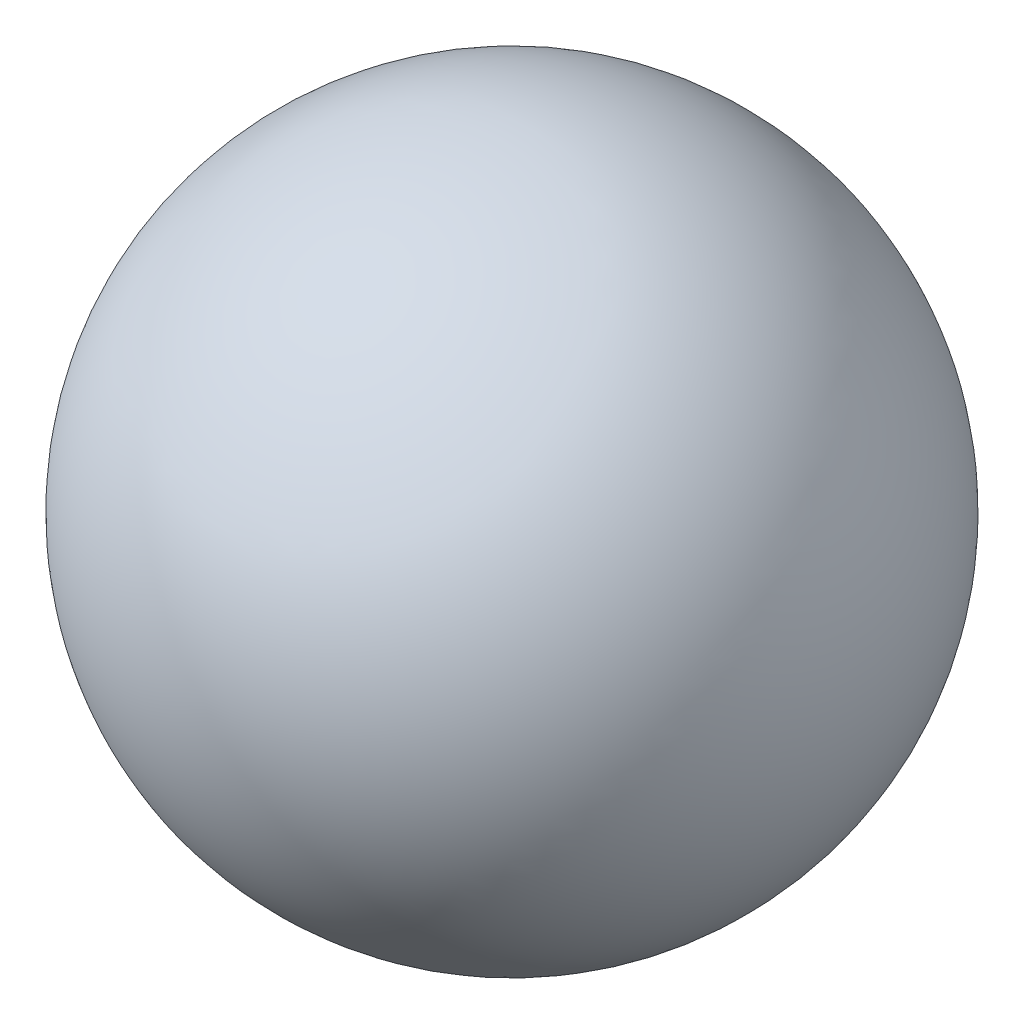
from build123d import *


with BuildPart() as part:
    # Esquisse1 → Révolution1 (revolve)
    with BuildSketch(Plane(origin=(0, 0, 0), x_dir=(1, 0, 0), z_dir=(0, 1, 0))):
        with BuildLine():
            Line((0, 6), (0, -6))
            ThreePointArc((0, -6), (-6, 0), (0, 6))
        make_face()
    revolve(axis=Axis((0, 0, -6), (0, 0, 1)))


solid = part.part
